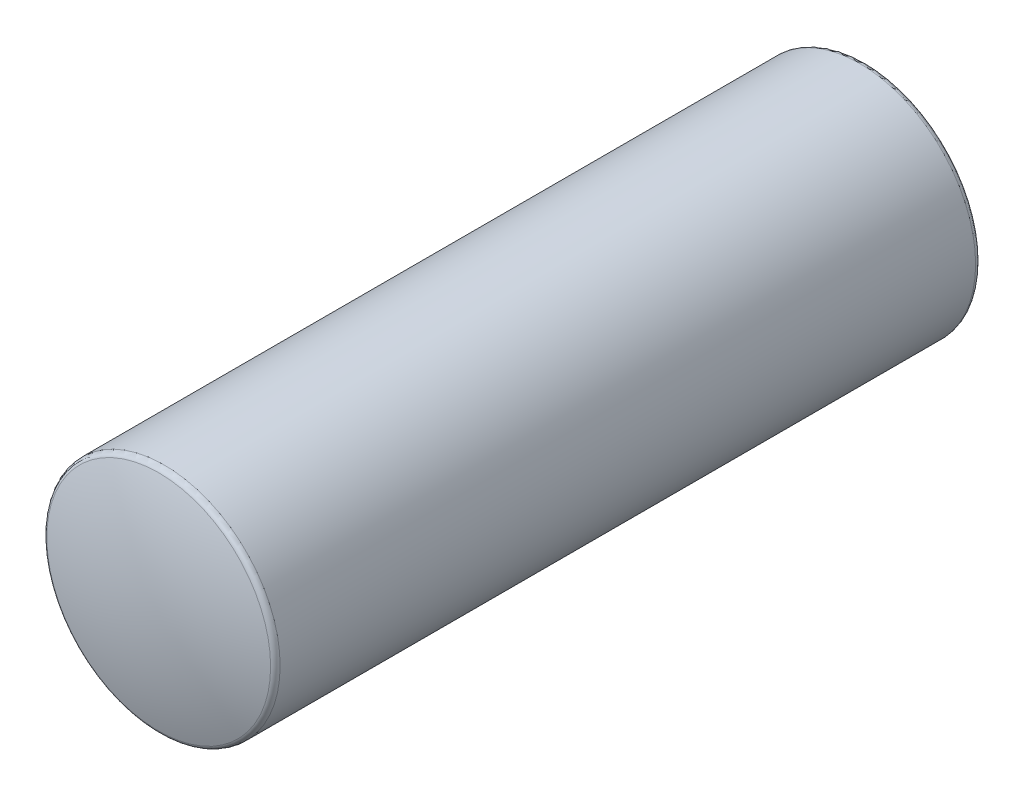
from build123d import *


with BuildPart() as part:
    # Szkic1 → Obr_t-cienka _cianka1 (revolve)
    with BuildSketch(Plane(origin=(0, 0, 0), x_dir=(0, 0, -1), z_dir=(1, 0, 0)), mode=Mode.PRIVATE) as obr_t_cienka_cianka1_sk:
        with BuildLine():
            ThreePointArc((-200, 0), (-161.657291364, 488.682730215), (-47.567567568, 965.405405405))
            ThreePointArc((-47.567567568, 965.405405405), (-29.408584884, 990.436804215), (0, 1000))
            Line((0, 1000), (6000, 1000))
            ThreePointArc((6000, 1000), (6029.408584884, 990.436804215), (6047.567567568, 965.405405405))
            ThreePointArc((6047.567567568, 965.405405405), (6161.657291364, 488.682730215), (6200, 0))
            Line((6200, 0), (6195, 0))
            ThreePointArc((6195, 0), (6156.718476538, 487.902917348), (6042.810810811, 963.864864865))
            ThreePointArc((6042.810810811, 963.864864865), (6026.467726395, 986.393123794), (6000, 995))
            Line((6000, 995), (0, 995))
            ThreePointArc((0, 995), (-26.467726395, 986.393123794), (-42.810810811, 963.864864865))
            ThreePointArc((-42.810810811, 963.864864865), (-156.718476538, 487.902917348), (-195, 0))
            Line((-195, 0), (-200, 0))
        make_face()
    revolve(obr_t_cienka_cianka1_sk.sketch.rotate(Axis((0, 0, 0), (0, 0, -1)), 90), axis=Axis((0, 0, 0), (0, 0, -1)))  # turned: the seam where the file's is


solid = part.part
